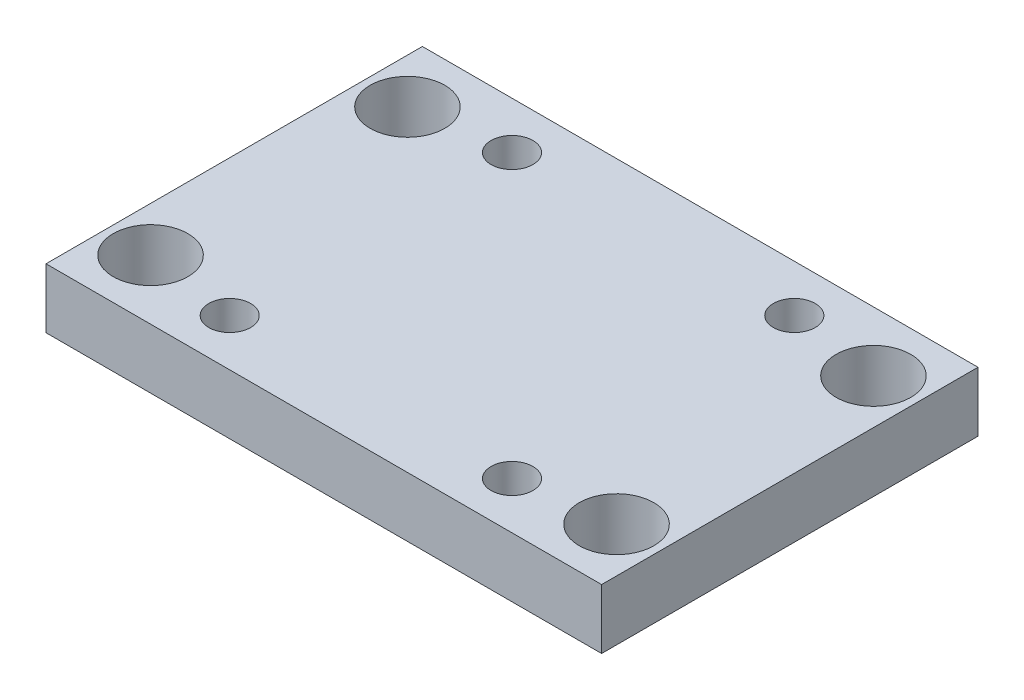
from build123d import *

# Parameters (mm, degrees)
SKETCH1_W           = 118.11
SKETCH1_H           = 80.01
BOSS_EXTRUDE1_DEPTH = 12.7
SKETCH2_R           = 4.445
CUT_EXTRUDE1_DEPTH  = 13.7
SKETCH3_R           = 7.9375
CUT_EXTRUDE2_DEPTH  = 13.7


with BuildPart() as part:
    # Sketch1 → Boss-Extrude1 (new body)
    with BuildSketch(Plane(origin=(0, 0, 0), x_dir=(1, 0, 0), z_dir=(0, 1, 0))):
        Rectangle(SKETCH1_W, SKETCH1_H)
    extrude(amount=BOSS_EXTRUDE1_DEPTH)

    # Sketch2 → Cut-Extrude1 (cut, through all)
    with BuildSketch(Plane.XZ):
        with Locations((-30.00502, 30.00502)):
            Circle(SKETCH2_R)
        with Locations((30.00502, 30.00502)):
            Circle(SKETCH2_R)
        with Locations((-30.00502, -30.00502)):
            Circle(SKETCH2_R)
        with Locations((30.00502, -30.00502)):
            Circle(SKETCH2_R)
    extrude(amount=-CUT_EXTRUDE1_DEPTH, mode=Mode.SUBTRACT)

    # Sketch3 → Cut-Extrude2 (cut, through all)
    with BuildSketch(Plane.XZ):
        with Locations((-49.53, 27.305)):
            Circle(SKETCH3_R)
        with Locations((-49.53, -27.305)):
            Circle(SKETCH3_R)
        with Locations((49.53, -27.305)):
            Circle(SKETCH3_R)
        with Locations((49.53, 27.305)):
            Circle(SKETCH3_R)
    extrude(amount=-CUT_EXTRUDE2_DEPTH, mode=Mode.SUBTRACT)


solid = part.part
